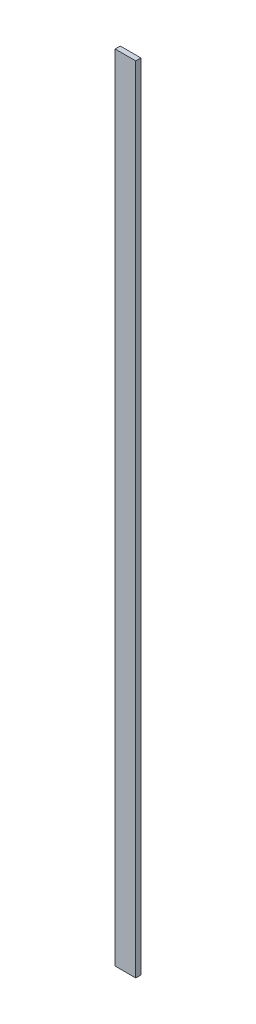
from build123d import *

# Parameters (mm, degrees)
ESQUISSE1_W        = 2
ESQUISSE1_H        = 77
BOSS_EXTRU_1_DEPTH = 0.5


with BuildPart() as part:
    # Esquisse1 → Boss.-Extru.1 (new body)
    with BuildSketch(Plane.XY):
        with Locations((1, -38.5)):
            Rectangle(ESQUISSE1_W, ESQUISSE1_H)
    extrude(amount=BOSS_EXTRU_1_DEPTH)


solid = part.part
